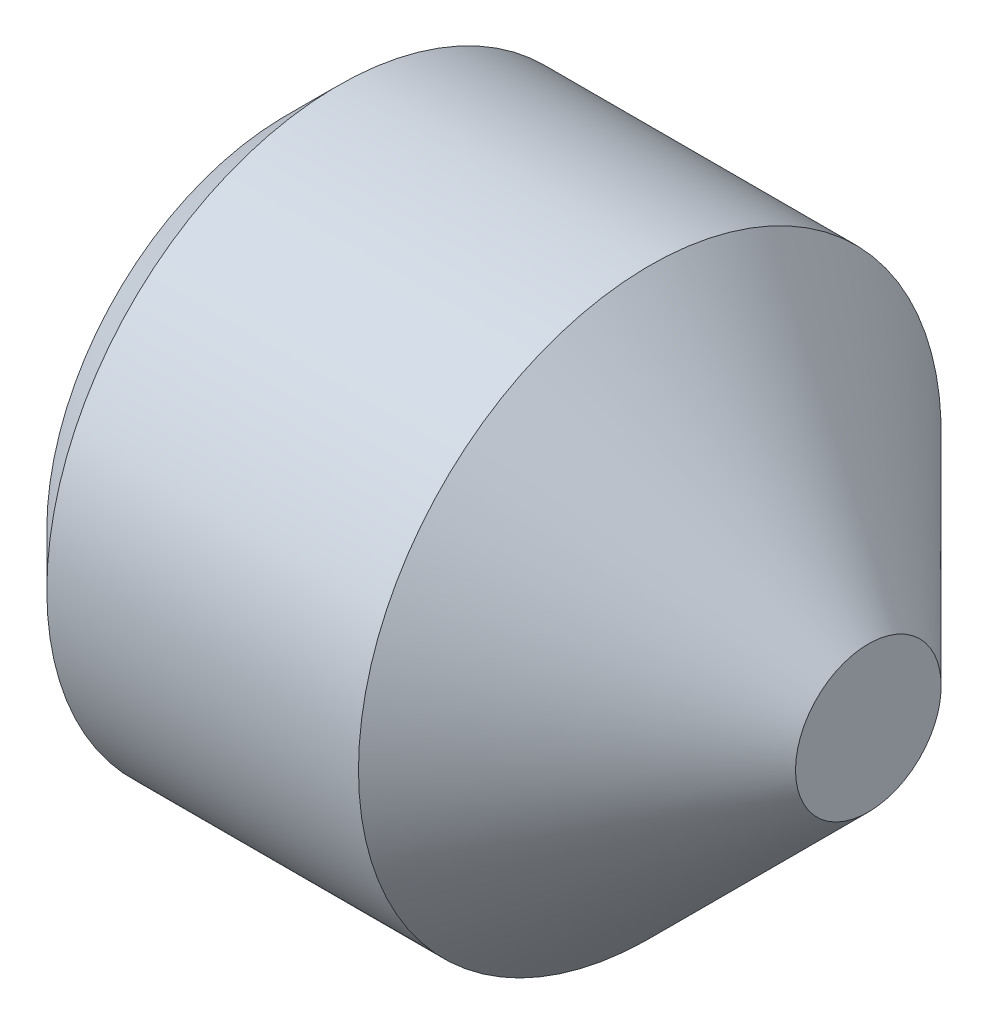
from build123d import *

# Parameters (mm, degrees)
HEXAGONSOCKET_DEPTH = 1.2


with BuildPart() as part:
    # Sketch1 → Base (revolve)
    with BuildSketch(Plane.XY):
        Polygon((0, 0), (3, 0), (3, 0.375), (1.875, 1.5), (0.2705, 1.5), (0, 1.2295), align=None)
    revolve(axis=Axis((-14.774129749, 0, 0), (1, 0, 0)))

    # Sketch2 → HexagonSocket (cut)
    with BuildSketch(Plane(origin=(0, 0.220293087, -0.139195271), x_dir=(0, 0, 1), z_dir=(-1, 0, 0))):
        Polygon((1.005220675, -0.220293087), (0.572207973, 0.529706913), (-0.293817431, 0.529706913), (-0.726830132, -0.220293087), (-0.293817431, -0.970293087), (0.572207973, -0.970293087), align=None)
    extrude(amount=-HEXAGONSOCKET_DEPTH, mode=Mode.SUBTRACT)

    # Sketch3 → Cut-Revolve (revolve, cut)
    with BuildSketch(Plane.XY):
        Polygon((1.2, 0.75), (1.633012702, 0), (1.2, 0), align=None)
    revolve(axis=Axis((1.2, 0, 0), (-1, 0, 0)), mode=Mode.SUBTRACT)


solid = part.part
